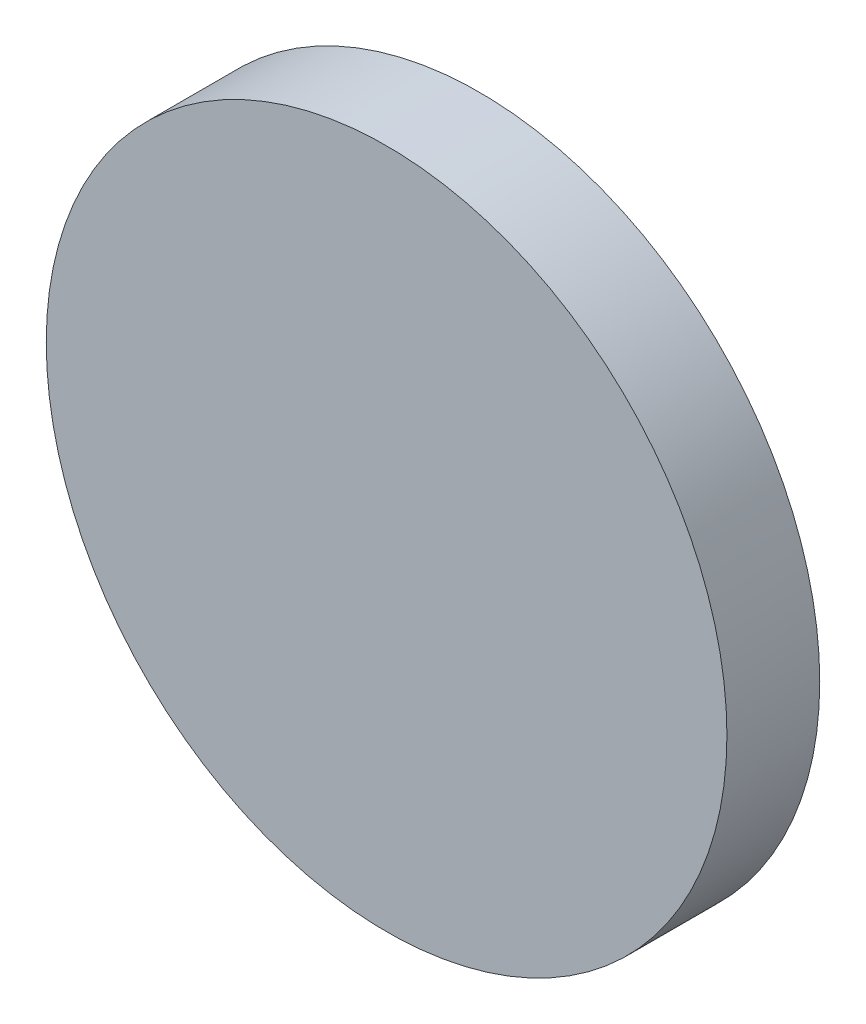
from build123d import *

# Parameters (mm, degrees)
SKETCH_1_R      = 11
EXTRUDE_4_DEPTH = 3


with BuildPart() as part:
    # Эскиз1 → Бобышка-Вытянуть4 (new body)
    with BuildSketch(Plane.XY):
        Circle(SKETCH_1_R)
    extrude(amount=EXTRUDE_4_DEPTH)


solid = part.part
